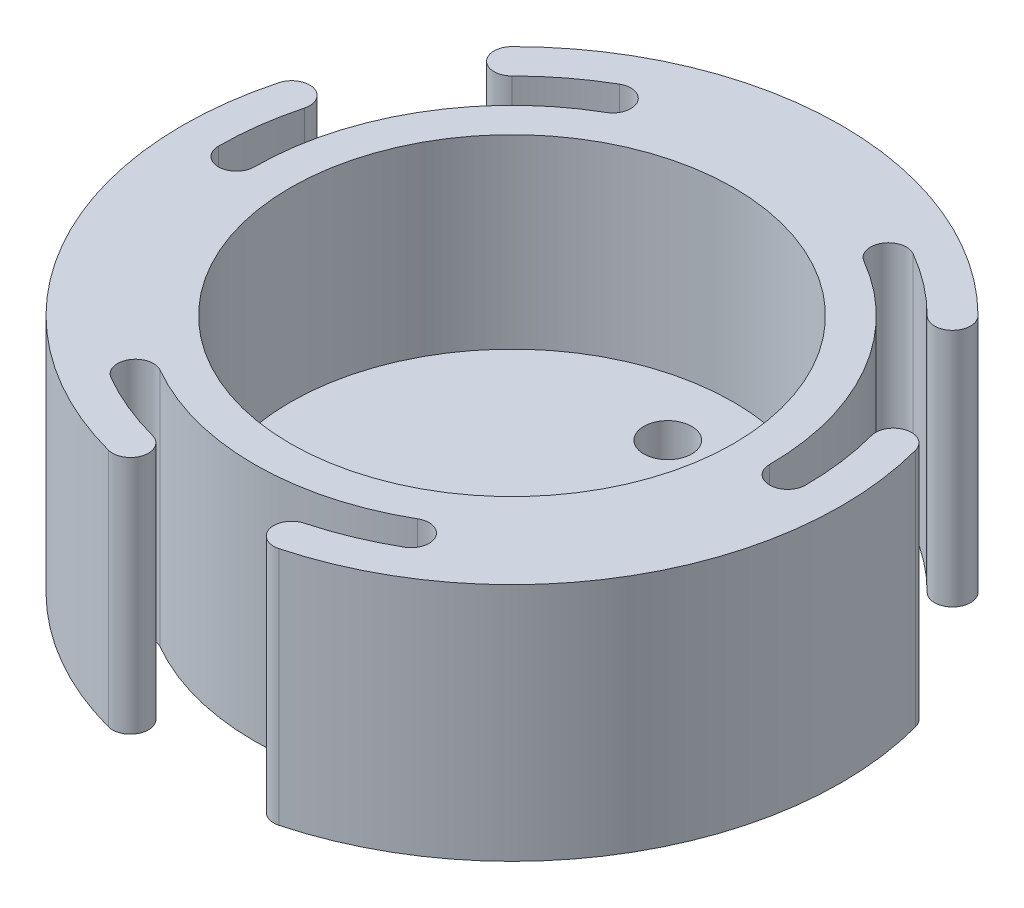
from build123d import *

# Parameters (mm, degrees)
ESQUISSE1_R             = 24.5
ESQUISSE1_R_2           = 18.5
BOSS_EXTRU_1_DEPTH      = 20
ENL_V_MAT_EXTRU_1_DEPTH = 21
BOSS_EXTRU_2_DEPTH      = 20
ESQUISSE4_R             = 21.5
BOSS_EXTRU_3_DEPTH      = 4.5
ENL_V_MAT_EXTRU_2_REACH = 6.5
ESQUISSE5_R             = 2


with BuildPart() as part:
    # Esquisse1 → Boss.-Extru.1 (new body)
    with BuildSketch(Plane(origin=(0, 0, 0), x_dir=(1, 0, 0), z_dir=(0, 1, 0))):
        Circle(ESQUISSE1_R)
        Circle(ESQUISSE1_R_2, mode=Mode.SUBTRACT)
    extrude(amount=BOSS_EXTRU_1_DEPTH)

    # Esquisse2 → Enlèv. mat.-Extru.1 (cut, through all)
    with BuildSketch(Plane(origin=(0, 20, 0), x_dir=(1, 0, 0), z_dir=(0, 1, 0))):
        with BuildLine():
            ThreePointArc((-12.25, 21.217622393), (-21.217622393, 12.25), (-24.5, 0))
            ThreePointArc((-24.5, 0), (-23, -1.5), (-21.5, 0))
            ThreePointArc((-21.5, 0), (-18.619546181, 10.75), (-10.75, 18.619546181))
            ThreePointArc((-10.75, 18.619546181), (-10.200961894, 20.668584287), (-12.25, 21.217622393))
        make_face()
        with BuildLine():
            ThreePointArc((24.5, 0), (21.217622393, 12.25), (12.25, 21.217622393))
            ThreePointArc((12.25, 21.217622393), (10.200961894, 20.668584287), (10.75, 18.619546181))
            ThreePointArc((10.75, 18.619546181), (18.619546181, 10.75), (21.5, 0))
            ThreePointArc((21.5, 0), (23, -1.5), (24.5, 0))
        make_face()
        with BuildLine():
            ThreePointArc((-12.25, -21.217622393), (0, -24.5), (12.25, -21.217622393))
            ThreePointArc((12.25, -21.217622393), (12.799038106, -19.168584287), (10.75, -18.619546181))
            ThreePointArc((10.75, -18.619546181), (0, -21.5), (-10.75, -18.619546181))
            ThreePointArc((-10.75, -18.619546181), (-12.799038106, -19.168584287), (-12.25, -21.217622393))
        make_face()
    extrude(amount=-ENL_V_MAT_EXTRU_1_DEPTH, mode=Mode.SUBTRACT)

    # Esquisse3 → Boss.-Extru.2 (add)
    with BuildSketch(Plane(origin=(0, 20, 0), x_dir=(1, 0, 0), z_dir=(0, 1, 0))):
        with BuildLine():
            ThreePointArc((19.445436483, 19.445436483), (0, 27.5), (-19.445436483, 19.445436483))
            ThreePointArc((-19.445436483, 19.445436483), (-19.445436483, 17.324116139), (-17.324116139, 17.324116139))
            ThreePointArc((-17.324116139, 17.324116139), (0, 24.5), (17.324116139, 17.324116139))
            ThreePointArc((17.324116139, 17.324116139), (19.445436483, 17.324116139), (19.445436483, 19.445436483))
        make_face()
        with BuildLine():
            ThreePointArc((7.11752374, -26.562960223), (23.815698604, -13.75), (26.562960223, 7.11752374))
            ThreePointArc((26.562960223, 7.11752374), (24.725842916, 8.178183912), (23.665182744, 6.341066605))
            ThreePointArc((23.665182744, 6.341066605), (21.217622393, -12.25), (6.341066605, -23.665182744))
            ThreePointArc((6.341066605, -23.665182744), (5.280406433, -25.502300051), (7.11752374, -26.562960223))
        make_face()
        with BuildLine():
            ThreePointArc((-26.562960223, 7.11752374), (-23.815698604, -13.75), (-7.11752374, -26.562960223))
            ThreePointArc((-7.11752374, -26.562960223), (-5.280406433, -25.502300051), (-6.341066605, -23.665182744))
            ThreePointArc((-6.341066605, -23.665182744), (-21.217622393, -12.25), (-23.665182744, 6.341066605))
            ThreePointArc((-23.665182744, 6.341066605), (-24.725842916, 8.178183912), (-26.562960223, 7.11752374))
        make_face()
    extrude(amount=-BOSS_EXTRU_2_DEPTH)

    # Esquisse4 → Boss.-Extru.3 (add)
    with BuildSketch(Plane.XZ):
        Circle(ESQUISSE4_R)
    extrude(amount=-BOSS_EXTRU_3_DEPTH)

    # Esquisse5 → Enlèv. mat.-Extru.2 (cut, up to next)
    with BuildSketch(Plane(origin=(0, 4.5, 0), x_dir=(1, 0, 0), z_dir=(0, 1, 0)), mode=Mode.PRIVATE) as enl_v_mat_extru_2_sk1:
        with Locations((0, 13)):
            Circle(ESQUISSE5_R)
    enl_v_mat_extru_2_tool1 = extrude(enl_v_mat_extru_2_sk1.sketch, amount=-ENL_V_MAT_EXTRU_2_REACH, mode=Mode.PRIVATE) & part.part
    add(enl_v_mat_extru_2_tool1.solids().sort_by_distance((0, 4.5, -13))[0], mode=Mode.SUBTRACT)
    # Esquisse5 → Enlèv. mat.-Extru.2 (cut, up to next)
    with BuildSketch(Plane(origin=(0, 4.5, 0), x_dir=(1, 0, 0), z_dir=(0, 1, 0)), mode=Mode.PRIVATE) as enl_v_mat_extru_2_sk2:
        with Locations((11.258330249, -6.5)):
            Circle(ESQUISSE5_R)
    enl_v_mat_extru_2_tool2 = extrude(enl_v_mat_extru_2_sk2.sketch, amount=-ENL_V_MAT_EXTRU_2_REACH, mode=Mode.PRIVATE) & part.part
    add(enl_v_mat_extru_2_tool2.solids().sort_by_distance((11.25833, 4.5, 6.5))[0], mode=Mode.SUBTRACT)
    # Esquisse5 → Enlèv. mat.-Extru.2 (cut, up to next)
    with BuildSketch(Plane(origin=(0, 4.5, 0), x_dir=(1, 0, 0), z_dir=(0, 1, 0)), mode=Mode.PRIVATE) as enl_v_mat_extru_2_sk3:
        with Locations((-11.258330249, -6.5)):
            Circle(ESQUISSE5_R)
    enl_v_mat_extru_2_tool3 = extrude(enl_v_mat_extru_2_sk3.sketch, amount=-ENL_V_MAT_EXTRU_2_REACH, mode=Mode.PRIVATE) & part.part
    add(enl_v_mat_extru_2_tool3.solids().sort_by_distance((-11.25833, 4.5, 6.5))[0], mode=Mode.SUBTRACT)


solid = part.part
